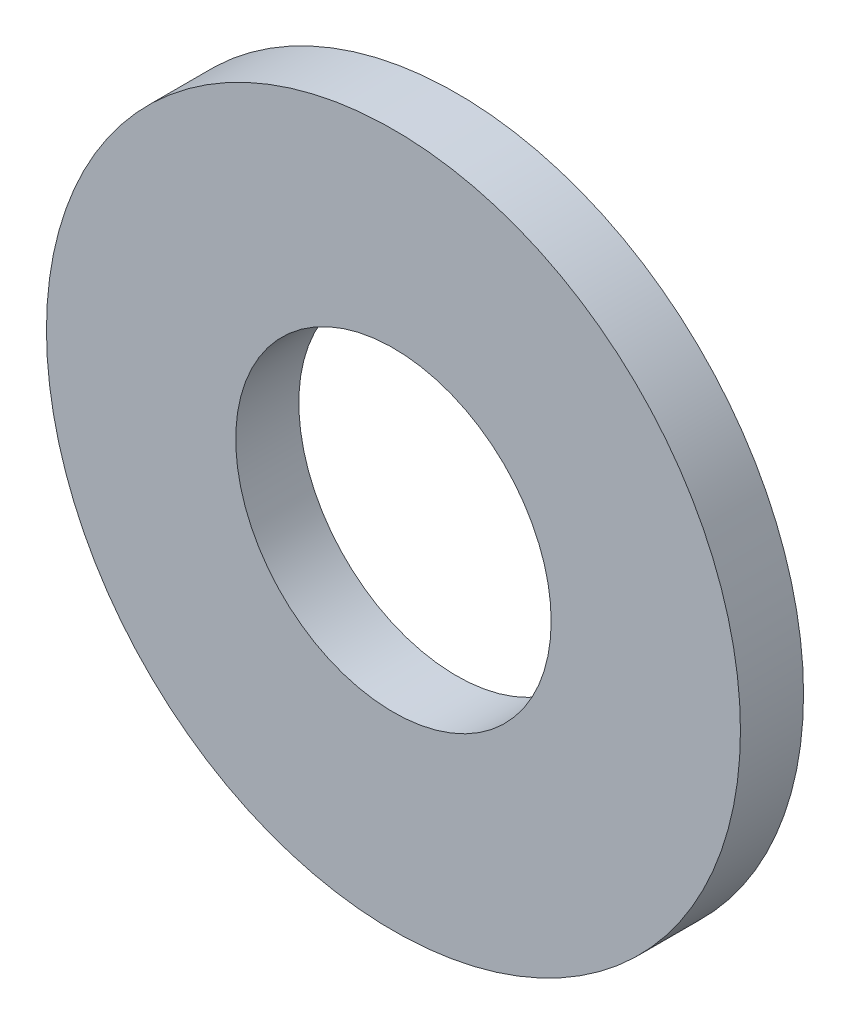
from build123d import *

# Parameters (mm, degrees)
ESQUISSE1_R        = 11
ESQUISSE1_R_2      = 5
BOSS_EXTRU_1_DEPTH = 2


with BuildPart() as part:
    # Esquisse1 → Boss.-Extru.1 (new body)
    with BuildSketch(Plane.XY):
        Circle(ESQUISSE1_R)
        Circle(ESQUISSE1_R_2, mode=Mode.SUBTRACT)
    extrude(amount=BOSS_EXTRU_1_DEPTH)


solid = part.part
